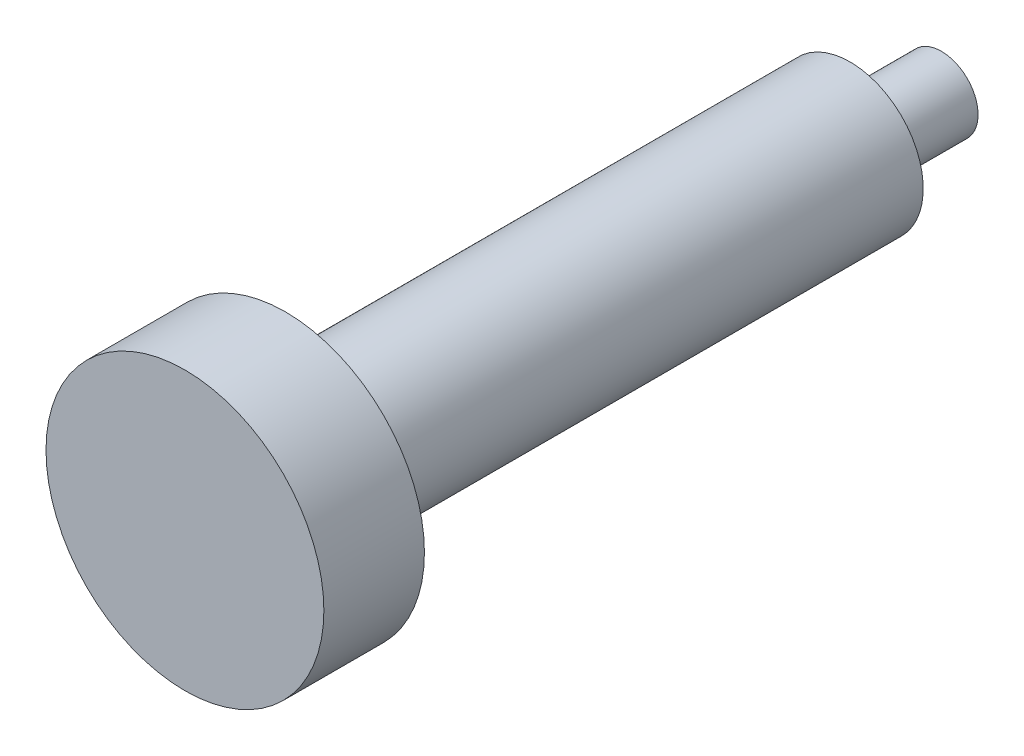
from build123d import *


with BuildPart() as part:
    # Skizze1 → Rotation1 (revolve)
    with BuildSketch(Plane(origin=(0, 0, 0), x_dir=(1, 0, 0), z_dir=(0, 1, 0)), mode=Mode.PRIVATE) as rotation1_sk:
        Polygon((0, 20), (8, 20), (8, 0), (16, 0), (16, -123.535), (30.4, -123.535), (30.4, -145.535), (0, -145.535), align=None)
    revolve(rotation1_sk.sketch.rotate(Axis((0, 0, -20), (0, 0, 1)), 180), axis=Axis((0, 0, -20), (0, 0, 1)))  # turned: the seam where the file's is


solid = part.part
